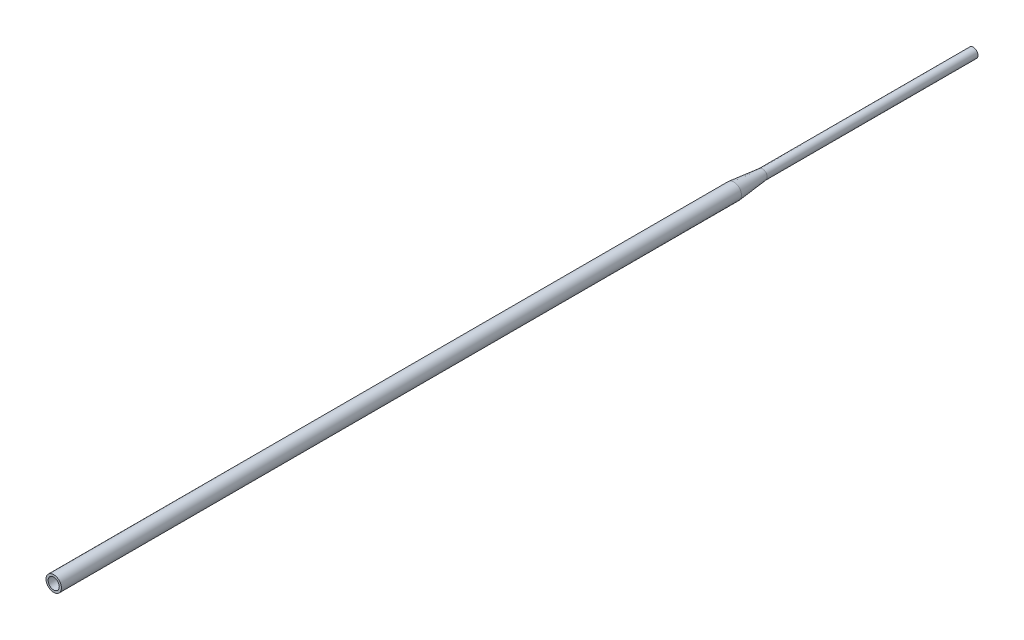
from build123d import *

# Parameters (mm, degrees)
SKETCH1_R           = 4.699
SKETCH1_R_2         = 3.75
BOSS_EXTRUDE1_DEPTH = 215.9
SKETCH6_R           = 7.62
SKETCH6_R_2         = 5.5
BOSS_EXTRUDE2_DEPTH = 671.6


with BuildPart() as part:
    # Sketch1 → Boss-Extrude1 (new body)
    with BuildSketch(Plane.XY):
        Circle(SKETCH1_R)
        Circle(SKETCH1_R_2, mode=Mode.SUBTRACT)
    extrude(amount=BOSS_EXTRUDE1_DEPTH)

    # Sketch5 → Revolve1 (revolve)
    with BuildSketch(Plane(origin=(0, 0, 0), x_dir=(1, 0, 0), z_dir=(0, 1, 0))):
        Polygon((-4.699, -208.123650762), (-7.62, -236.448520775), (-5.08, -236.448520775), (-5.08, -245.9), (-3.58, -245.9), (-3.58, -215.9), (-4.699, -215.9), align=None)
    revolve(axis=Axis((0, 0, 215.9), (0, 0, 1)))

    # Sketch6 → Boss-Extrude2 (add)
    with BuildSketch(Plane.XY.offset(236.448520775)):
        Circle(SKETCH6_R)
        Circle(SKETCH6_R_2, mode=Mode.SUBTRACT)
    extrude(amount=BOSS_EXTRUDE2_DEPTH)


solid = part.part
